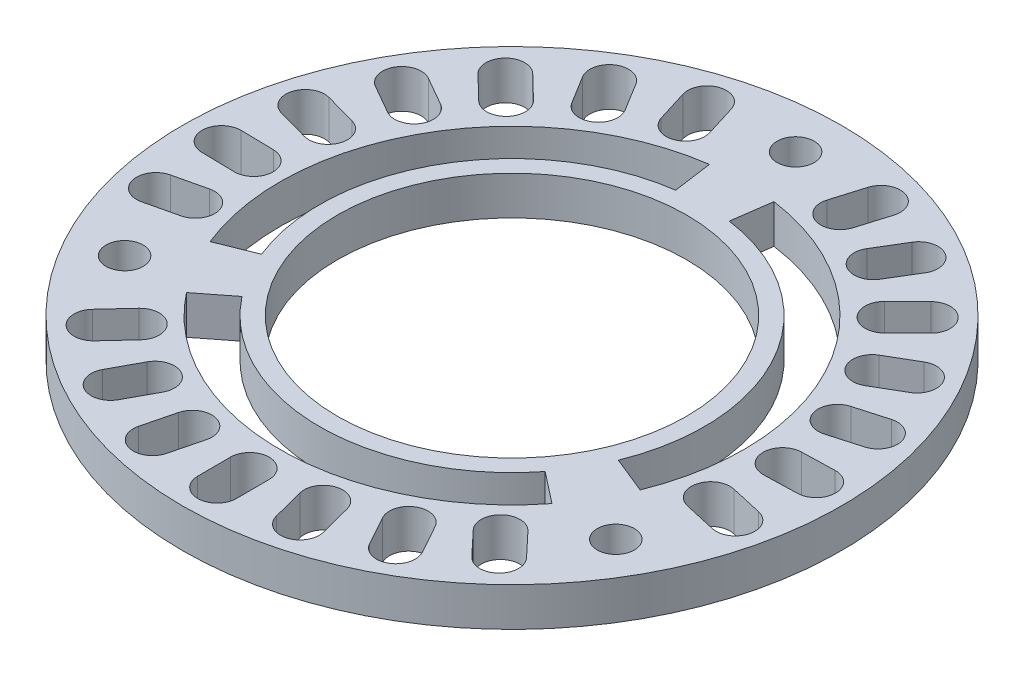
from build123d import *

# Parameters (mm, degrees)
SKETCH1_R           = 21.59
SKETCH1_R_2         = 11.43
SKETCH1_R_3         = 1.217304979
BOSS_EXTRUDE1_DEPTH = 2.54


with BuildPart() as part:
    # Sketch1 → Boss-Extrude1 (new body)
    with BuildSketch(Plane(origin=(0, 0, 0), x_dir=(1, 0, 0), z_dir=(0, 1, 0))):
        with Locations(Location((-126.227589866, 73.421482023, 0), (0, 0, 270))):  # turned: the seam where the file's is
            Circle(SKETCH1_R)
        with Locations(Location((-126.227589866, 73.421482023, 0), (0, 0, 270))):  # turned: the seam where the file's is
            Circle(SKETCH1_R_2, mode=Mode.SUBTRACT)
        with Locations(Location((-126.227589866, 92.001159833, 0), (0, 0, 270))):  # turned: the seam where the file's is
            Circle(SKETCH1_R_3, mode=Mode.SUBTRACT)
        with Locations(Location((-110.137116889, 64.131643118, 0), (0, 0, 270))):  # turned: the seam where the file's is
            Circle(SKETCH1_R_3, mode=Mode.SUBTRACT)
        with Locations(Location((-142.318062844, 64.131643118, 0), (0, 0, 270))):  # turned: the seam where the file's is
            Circle(SKETCH1_R_3, mode=Mode.SUBTRACT)
        with BuildLine():
            Line((-124.112850648, 88.468633425), (-124.473677215, 85.901218995))
            ThreePointArc((-124.473677215, 85.901218995), (-115.31360648, 79.722673269), (-114.542864291, 68.700546449))
            Line((-114.542864291, 68.700546449), (-112.139004888, 67.729324207))
            ThreePointArc((-112.139004888, 67.729324207), (-113.068309283, 81.01899621), (-124.112850648, 88.468633425))
        make_face(mode=Mode.SUBTRACT)
        with BuildLine():
            Line((-119.418746821, 91.635534611), (-120.038701331, 89.576664888))
            ThreePointArc((-120.038701331, 89.576664888), (-121.618568384, 88.728048279), (-122.467184992, 90.307915332))
            Line((-122.467184992, 90.307915332), (-121.847230483, 92.366785055))
            ThreePointArc((-121.847230483, 92.366785055), (-120.26736343, 93.215401663), (-119.418746821, 91.635534611))
        make_face(mode=Mode.SUBTRACT)
        with BuildLine():
            Line((-115.121572952, 89.382949486), (-116.231928828, 87.541646155))
            ThreePointArc((-116.231928828, 87.541646155), (-117.972703409, 87.110561582), (-118.403787983, 88.851336163))
            Line((-118.403787983, 88.851336163), (-117.293432106, 90.692639495))
            ThreePointArc((-117.293432106, 90.692639495), (-115.552657525, 91.123724068), (-115.121572952, 89.382949486))
        make_face(mode=Mode.SUBTRACT)
        with BuildLine():
            Line((-111.515818176, 86.136663069), (-113.047448813, 84.627558791))
            ThreePointArc((-113.047448813, 84.627558791), (-114.840756806, 84.640843967), (-114.827471629, 86.43415196))
            Line((-114.827471629, 86.43415196), (-113.295840992, 87.943256238))
            ThreePointArc((-113.295840992, 87.943256238), (-111.502532999, 87.929971061), (-111.515818176, 86.136663069))
        make_face(mode=Mode.SUBTRACT)
        with BuildLine():
            Line((-108.825963306, 82.098777014), (-110.683515106, 81.01582298))
            ThreePointArc((-110.683515106, 81.01582298), (-112.417711859, 81.472650821), (-111.960884018, 83.206847573))
            Line((-111.960884018, 83.206847573), (-110.103332218, 84.289801607))
            ThreePointArc((-110.103332218, 84.289801607), (-108.369135466, 83.832973767), (-108.825963306, 82.098777014))
        make_face(mode=Mode.SUBTRACT)
        with BuildLine():
            Line((-107.219468651, 77.520675013), (-109.287297384, 76.931291893))
            ThreePointArc((-109.287297384, 76.931291893), (-110.854418289, 77.803222004), (-109.982488178, 79.37034291))
            Line((-109.982488178, 79.37034291), (-107.914659445, 79.95972603))
            ThreePointArc((-107.914659445, 79.95972603), (-106.34753854, 79.087795919), (-107.219468651, 77.520675013))
        make_face(mode=Mode.SUBTRACT)
        with BuildLine():
            Line((-106.796348562, 72.687372581), (-108.945718941, 72.628253164))
            ThreePointArc((-108.945718941, 72.628253164), (-110.24820091, 73.861002437), (-109.015451637, 75.163484407))
            Line((-109.015451637, 75.163484407), (-106.866081259, 75.222603824))
            ThreePointArc((-106.866081259, 75.222603824), (-105.563599289, 73.989854551), (-106.796348562, 72.687372581))
        make_face(mode=Mode.SUBTRACT)
        with BuildLine():
            Line((-107.582944914, 67.899773058), (-109.680045174, 68.374597899))
            ThreePointArc((-109.680045174, 68.374597899), (-110.63680055, 69.891419972), (-109.119978476, 70.848175348))
            Line((-109.119978476, 70.848175348), (-107.022878216, 70.373350508))
            ThreePointArc((-107.022878216, 70.373350508), (-106.06612284, 68.856528434), (-107.582944914, 67.899773058))
        make_face(mode=Mode.SUBTRACT)
        with BuildLine():
            Line((-138.201435626, 64.066488437), (-136.158402791, 65.662680625))
            ThreePointArc((-136.158402791, 65.662680625), (-126.227589866, 60.819099531), (-116.296776942, 65.662680625))
            Line((-116.296776942, 65.662680625), (-114.253744106, 64.066488437))
            ThreePointArc((-114.253744106, 64.066488437), (-126.227589866, 58.226453649), (-138.201435626, 64.066488437))
        make_face(mode=Mode.SUBTRACT)
        with BuildLine():
            Line((-113.858179141, 58.417824681), (-115.331235369, 59.984155898))
            ThreePointArc((-115.331235369, 59.984155898), (-115.276225385, 61.776669204), (-113.483712078, 61.721659219))
            Line((-113.483712078, 61.721659219), (-112.01065585, 60.155328003))
            ThreePointArc((-112.01065585, 60.155328003), (-112.065665835, 58.362814697), (-113.858179141, 58.417824681))
        make_face(mode=Mode.SUBTRACT)
        with BuildLine():
            Line((-117.957562018, 55.822655508), (-118.996999541, 57.70490357))
            ThreePointArc((-118.996999541, 57.70490357), (-118.499942442, 59.428000866), (-116.776845146, 58.930943767))
            Line((-116.776845146, 58.930943767), (-115.737407623, 57.048695705))
            ThreePointArc((-115.737407623, 57.048695705), (-116.234464722, 55.325598409), (-117.957562018, 55.822655508))
        make_face(mode=Mode.SUBTRACT)
        with BuildLine():
            Line((-122.571805912, 54.323123481), (-123.112913235, 56.404106661))
            ThreePointArc((-123.112913235, 56.404106661), (-122.204753938, 57.950514351), (-120.658346248, 57.042355055))
            Line((-120.658346248, 57.042355055), (-120.117238925, 54.961371875))
            ThreePointArc((-120.117238925, 54.961371875), (-121.025398222, 53.414964185), (-122.571805912, 54.323123481))
        make_face(mode=Mode.SUBTRACT)
        with BuildLine():
            Line((-127.413645248, 54.012583859), (-127.422735052, 56.162747924))
            ThreePointArc((-127.422735052, 56.162747924), (-126.16001216, 57.436192446), (-124.886567638, 56.173469555))
            Line((-124.886567638, 56.173469555), (-124.877477834, 54.02330549))
            ThreePointArc((-124.877477834, 54.02330549), (-126.140200725, 52.749860968), (-127.413645248, 54.012583859))
        make_face(mode=Mode.SUBTRACT)
        with BuildLine():
            Line((-132.181645209, 54.910369677), (-131.658151598, 56.99585345))
            ThreePointArc((-131.658151598, 56.99585345), (-130.119477518, 57.91705491), (-129.198276059, 56.37838083))
            Line((-129.198276059, 56.37838083), (-129.72176967, 54.292897057))
            ThreePointArc((-129.72176967, 54.292897057), (-131.26044375, 53.371695598), (-132.181645209, 54.910369677))
        make_face(mode=Mode.SUBTRACT)
        with BuildLine():
            Line((-136.578967944, 56.960588147), (-135.555481672, 58.851557206))
            ThreePointArc((-135.555481672, 58.851557206), (-133.8366485, 59.363165043), (-133.325040663, 57.644331871))
            Line((-133.325040663, 57.644331871), (-134.348526935, 55.753362813))
            ThreePointArc((-134.348526935, 55.753362813), (-136.067360107, 55.241754975), (-136.578967944, 56.960588147))
        make_face(mode=Mode.SUBTRACT)
        with BuildLine():
            Line((-140.331852578, 60.035600332), (-138.872092074, 61.614330011))
            ThreePointArc((-138.872092074, 61.614330011), (-137.080107937, 61.684493435), (-137.009944513, 59.892509298))
            Line((-137.009944513, 59.892509298), (-138.469705017, 58.313779619))
            ThreePointArc((-138.469705017, 58.313779619), (-140.261689154, 58.243616195), (-140.331852578, 60.035600332))
        make_face(mode=Mode.SUBTRACT)
        with BuildLine():
            Line((-128.342329084, 88.468633425), (-127.981502517, 85.901218995))
            ThreePointArc((-127.981502517, 85.901218995), (-137.141573252, 79.722673269), (-137.912315442, 68.700546449))
            Line((-137.912315442, 68.700546449), (-140.316174844, 67.729324207))
            ThreePointArc((-140.316174844, 67.729324207), (-139.386870449, 81.01899621), (-128.342329084, 88.468633425))
        make_face(mode=Mode.SUBTRACT)
        with BuildLine():
            Line((-145.405843636, 70.211086776), (-143.312832898, 70.703625283))
            ThreePointArc((-143.312832898, 70.703625283), (-141.78797583, 69.759728585), (-142.731872528, 68.234871518))
            Line((-142.731872528, 68.234871518), (-144.824883266, 67.742333011))
            ThreePointArc((-144.824883266, 67.742333011), (-146.349740334, 68.686229709), (-145.405843636, 70.211086776))
        make_face(mode=Mode.SUBTRACT)
        with BuildLine():
            Line((-145.603634629, 75.058841074), (-143.45384123, 75.017896343))
            ThreePointArc((-143.45384123, 75.017896343), (-142.210123747, 73.72588362), (-143.502136471, 72.482166138))
            Line((-143.502136471, 72.482166138), (-145.65192987, 72.523110869))
            ThreePointArc((-145.65192987, 72.523110869), (-146.895647352, 73.815123592), (-145.603634629, 75.058841074))
        make_face(mode=Mode.SUBTRACT)
        with BuildLine():
            Line((-144.595145511, 79.804659518), (-142.522407551, 79.232780616))
            ThreePointArc((-142.522407551, 79.232780616), (-141.637258855, 77.67308775), (-143.196951721, 76.787939054))
            Line((-143.196951721, 76.787939054), (-145.269689681, 77.359817956))
            ThreePointArc((-145.269689681, 77.359817956), (-146.154838377, 78.919510823), (-144.595145511, 79.804659518))
        make_face(mode=Mode.SUBTRACT)
        with BuildLine():
            Line((-142.443161045, 84.153085195), (-140.57651944, 83.085875164))
            ThreePointArc((-140.57651944, 83.085875164), (-140.105045579, 81.355602801), (-141.835317942, 80.88412894))
            Line((-141.835317942, 80.88412894), (-143.701959547, 81.951338971))
            ThreePointArc((-143.701959547, 81.951338971), (-144.173433408, 83.681611334), (-142.443161045, 84.153085195))
        make_face(mode=Mode.SUBTRACT)
        with BuildLine():
            Line((-139.281655738, 87.833401378), (-137.737320617, 86.337300725))
            ThreePointArc((-137.737320617, 86.337300725), (-137.708873791, 84.544169154), (-139.502005362, 84.515722328))
            Line((-139.502005362, 84.515722328), (-141.046340483, 86.011822981))
            ThreePointArc((-141.046340483, 86.011822981), (-141.074787309, 87.804954552), (-139.281655738, 87.833401378))
        make_face(mode=Mode.SUBTRACT)
        with BuildLine():
            Line((-135.307453093, 90.61648534), (-134.181568986, 88.784635699))
            ThreePointArc((-134.181568986, 88.784635699), (-134.597920188, 87.040278588), (-136.342277299, 87.45662979))
            Line((-136.342277299, 87.45662979), (-137.468161405, 89.288479432))
            ThreePointArc((-137.468161405, 89.288479432), (-137.051810203, 91.032836542), (-135.307453093, 90.61648534))
        make_face(mode=Mode.SUBTRACT)
        with BuildLine():
            Line((-130.767972107, 92.329072679), (-130.130632351, 90.275518159))
            ThreePointArc((-130.130632351, 90.275518159), (-130.965861112, 88.688532661), (-132.552846609, 89.523761422))
            Line((-132.552846609, 89.523761422), (-133.190186365, 91.577315942))
            ThreePointArc((-133.190186365, 91.577315942), (-132.354957605, 93.164301439), (-130.767972107, 92.329072679))
        make_face(mode=Mode.SUBTRACT)
    extrude(amount=BOSS_EXTRUDE1_DEPTH)


solid = part.part
